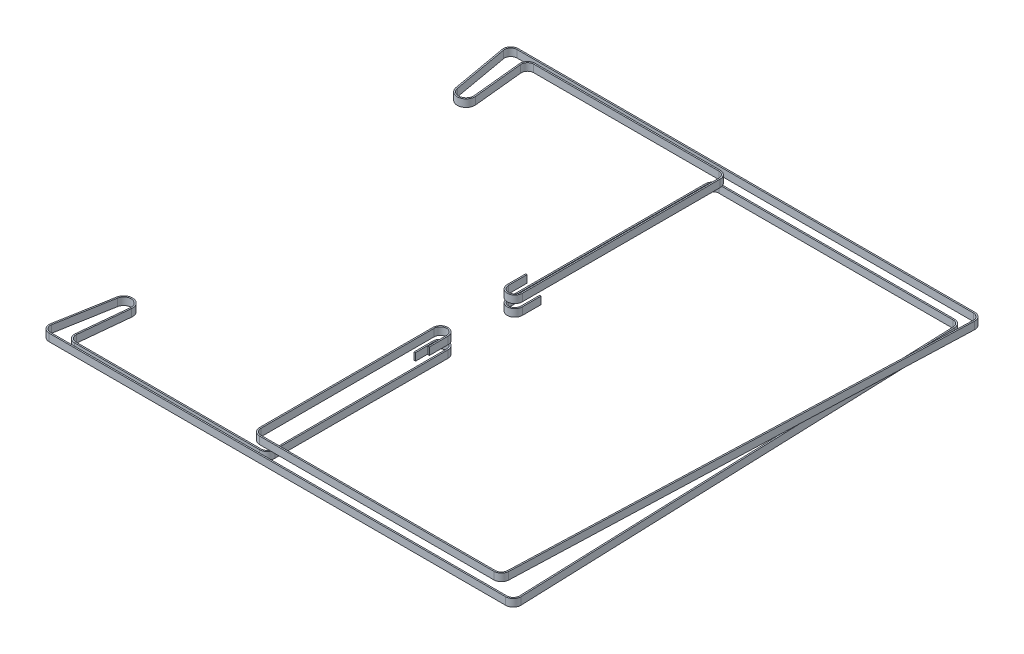
from build123d import *

# Parameters (mm, degrees)
CROQUIS3_W = 1.1
CROQUIS3_H = 6
CROQUIS5_W = 1.1
CROQUIS5_H = 6


with BuildPart() as part:
    # Barrer1: sweep along a path in Croquis2
    with BuildLine(Plane(origin=(0, 336.5, 0), x_dir=(1, 0, 0), z_dir=(0, 1, 0))) as barrer1_path:
        Line((-2.853911117, -54.994524715), (-2.853911117, -39.994524715))
        ThreePointArc((-2.853911117, -39.994524715), (3.246088883, -33.894524715), (9.346088883, -39.994524715))
        Line((9.346088883, -39.994524715), (9.346088883, -179.5))
        ThreePointArc((9.346088883, -179.5), (7.559440248, -183.813351365), (3.246088883, -185.6))
        Line((3.246088883, -185.6), (-146, -185.6))
        ThreePointArc((-146, -185.6), (-150.523380854, -183.592557348), (-152.069572313, -178.891483819))
        Line((-152.069572313, -178.891483819), (-148.029928873, -138.598540506))
        ThreePointArc((-148.029928873, -138.598540506), (-153.176033769, -132.056845985), (-159.907728075, -136.951787718))
        Line((-159.907728075, -136.951787718), (-167.923106729, -182.126489765))
        ThreePointArc((-167.923106729, -182.126489765), (-166.831941491, -186.211887983), (-163, -188))
        Line((-163, -188), (205, -188))
        ThreePointArc((205, -188), (208.598331263, -186.471600801), (209.996787878, -182.820804849))
        Line((209.996787878, -182.820804849), (196.996787878, 179.679195151))
        ThreePointArc((196.996787878, 179.679195151), (195.471600801, 183.098331263), (192, 184.5))
        Line((192, 184.5), (3.246088883, 184.5))
        ThreePointArc((3.246088883, 184.5), (-0.289445023, 183.035533906), (-1.753911117, 179.5))
        Line((-1.753911117, 179.5), (-1.753911117, 20.005475285))
        ThreePointArc((-1.753911117, 20.005475285), (3.246088883, 15.005475285), (8.246088883, 20.005475285))
        Line((8.246088883, 20.005475285), (8.246088883, 35.005475285))
    # Croquis3 → Barrer1 (sweep)
    with BuildSketch(Plane.XY.offset(54.994524715)):
        with Locations((-2.303911117, 339.5)):
            Rectangle(CROQUIS3_W, CROQUIS3_H)
    sweep(path=barrer1_path.line)


with BuildPart() as body_2:
    # Barrer2: sweep along a path in Croquis4
    with BuildLine(Plane(origin=(0, 346, 0), x_dir=(1, 0, 0), z_dir=(0, 1, 0))) as barrer2_path:
        Line((-2.853911117, 35.005475285), (-2.853911117, 20.005475285))
        ThreePointArc((-2.853911117, 20.005475285), (3.246088883, 13.905475285), (9.346088883, 20.005475285))
        Line((9.346088883, 20.005475285), (9.346088883, 179.5))
        ThreePointArc((9.346088883, 179.5), (7.559440248, 183.813351365), (3.246088883, 185.6))
        Line((3.246088883, 185.6), (-146, 185.6))
        ThreePointArc((-146, 185.6), (-150.523380854, 183.592557348), (-152.069572313, 178.891483819))
        Line((-152.069572313, 178.891483819), (-148.029928873, 138.598540506))
        ThreePointArc((-148.029928873, 138.598540506), (-153.176033769, 132.056845985), (-159.907728075, 136.951787718))
        Line((-159.907728075, 136.951787718), (-167.923106655, 182.126489344))
        ThreePointArc((-167.923106655, 182.126489344), (-166.831941337, 186.211887854), (-162.999999572, 188))
        Line((-162.999999572, 188), (205, 188))
        ThreePointArc((205, 188), (208.598331263, 186.471600801), (209.996787878, 182.820804849))
        Line((209.996787878, 182.820804849), (196.996787878, -179.679195151))
        ThreePointArc((196.996787878, -179.679195151), (195.471600801, -183.098331263), (192, -184.5))
        Line((192, -184.5), (3.246088883, -184.5))
        ThreePointArc((3.246088883, -184.5), (-0.289445023, -183.035533906), (-1.753911117, -179.5))
        Line((-1.753911117, -179.5), (-1.753911117, -39.994524715))
        ThreePointArc((-1.753911117, -39.994524715), (3.246088883, -34.994524715), (8.246088883, -39.994524715))
        Line((8.246088883, -39.994524715), (8.246088883, -54.994524715))
    # Croquis5 → Barrer2 (sweep)
    with BuildSketch(Plane.XY.offset(-35.005475285)):
        with Locations((-2.303911117, 349)):
            Rectangle(CROQUIS5_W, CROQUIS5_H)
    sweep(path=barrer2_path.line)


solid = Compound([part.part, body_2.part])
